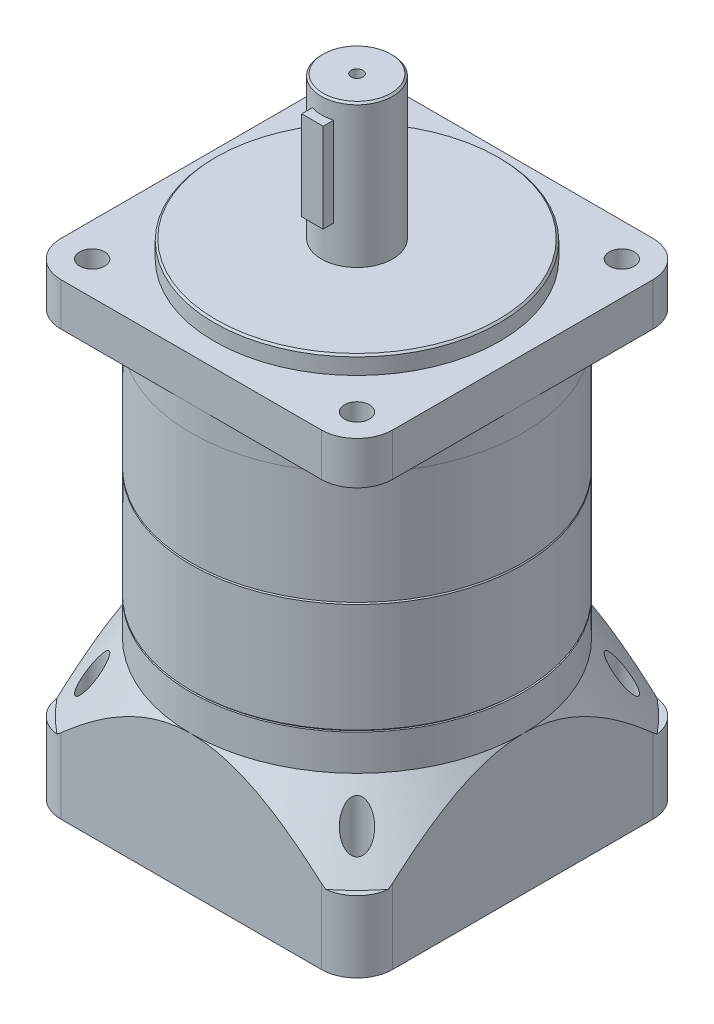
from build123d import *

# Parameters (mm, degrees)
EXTRUDE_1_DEPTH               = 49
CUT_EXTRUDE_START             = -10
SKETCH_2_OUTSIDE_W            = 123.07
SKETCH_2_OUTSIDE_H            = 123.07
SKETCH_2_OUTSIDE_R            = 46.5
CUT_EXTRUDE_3_DEPTH           = 10
CUT_EXTRUDE_3_OTHER_WAY_DEPTH = 19
CUT_EXTRUDE_3_OTHER_WAY_TAPER = 35
SKETCH_3_R                    = 46.5
EXTRUDE_2_DEPTH               = 31.5
SKETCH_18_R                   = 46.5
EXTRUDE_9_DEPTH               = 31.5
SKETCH_4_R                    = 46.5
EXTRUDE_3_DEPTH               = 19
CHAMFER_1_SIZE                = 0.5
SKETCH_6_R                    = 40
EXTRUDE_5_DEPTH               = 5
SKETCH_7_R                    = 10
EXTRUDE_6_DEPTH               = 40
CHAMFER_2_SIZE                = 0.5
SKETCH_10_W                   = 6
SKETCH_10_H                   = 25
EXTRUDE_7_DEPTH               = 12.5
SKETCH_11_R                   = 35
CUT_EXTRUDE_4_DEPTH           = 6
SKETCH_12_R                   = 10
CUT_EXTRUDE_5_DEPTH           = 40
SKETCH_15_R                   = 44.756471123
EXTRUDE_8_DEPTH               = 12
SKETCH_16_W                   = 3.5
SKETCH_16_H                   = 131
PATTERN_CIRCULAR_1_COUNT      = 4


with BuildPart() as part:
    # 草圖1 → 填料-伸長1 (new body)
    with BuildSketch(Plane(origin=(0, 0, 0), x_dir=(1, 0, 0), z_dir=(0, 1, 0))):
        with BuildLine():
            Line((-36.5, -46.5), (36.5, -46.5))
            ThreePointArc((36.5, -46.5), (43.571067812, -43.571067812), (46.5, -36.5))
            Line((46.5, -36.5), (46.5, 36.5))
            ThreePointArc((46.5, 36.5), (43.571067812, 43.571067812), (36.5, 46.5))
            Line((36.5, 46.5), (-36.5, 46.5))
            ThreePointArc((-36.5, 46.5), (-43.571067812, 43.571067812), (-46.5, 36.5))
            Line((-46.5, 36.5), (-46.5, -36.5))
            ThreePointArc((-46.5, -36.5), (-43.571067812, -43.571067812), (-36.5, -46.5))
        make_face()
    extrude(amount=EXTRUDE_1_DEPTH)

    # 草圖2 outside → 除料-伸長3 (cut)
    with BuildSketch(Plane(origin=(0, 49, 0), x_dir=(1, 0, 0), z_dir=(0, 1, 0)).offset(CUT_EXTRUDE_START)):
        Rectangle(SKETCH_2_OUTSIDE_W, SKETCH_2_OUTSIDE_H)
        with Locations(Location((0, 0, 0), (0, 0, 270))):  # turned: the seam where the file's is
            Circle(SKETCH_2_OUTSIDE_R, mode=Mode.SUBTRACT)
    extrude(amount=CUT_EXTRUDE_3_DEPTH, mode=Mode.SUBTRACT)

    # 草圖2 outside → 除料-伸長3 other way (cut)
    with BuildSketch(Plane(origin=(0, 49, 0), x_dir=(1, 0, 0), z_dir=(0, 1, 0)).offset(CUT_EXTRUDE_START)):
        Rectangle(SKETCH_2_OUTSIDE_W, SKETCH_2_OUTSIDE_H)
        with Locations(Location((0, 0, 0), (0, 0, 270))):  # turned: the seam where the file's is
            Circle(SKETCH_2_OUTSIDE_R, mode=Mode.SUBTRACT)
    extrude(amount=-CUT_EXTRUDE_3_OTHER_WAY_DEPTH, taper=CUT_EXTRUDE_3_OTHER_WAY_TAPER, mode=Mode.SUBTRACT)

    # 草圖11 → 除料-伸長4 (cut)
    with BuildSketch(Plane.XZ):
        with Locations(Location((0, 0, 0), (0, 0, 270))):  # turned: the seam where the file's is
            Circle(SKETCH_11_R)
    extrude(amount=-CUT_EXTRUDE_4_DEPTH, mode=Mode.SUBTRACT)

    # 草圖12 → 除料-伸長5 (cut)
    with BuildSketch(Plane.XZ.offset(-6)):
        with Locations(Location((0, 0, 0), (0, 0, 90))):  # turned: the seam where the file's is
            Circle(SKETCH_12_R)
    extrude(amount=-CUT_EXTRUDE_5_DEPTH, mode=Mode.SUBTRACT)


with BuildPart() as body_2:
    # 草圖3 → 填料-伸長2 (new body)
    with BuildSketch(Plane(origin=(0, 49, 0), x_dir=(1, 0, 0), z_dir=(0, 1, 0))):
        with Locations(Location((0, 0, 0), (0, 0, 270))):  # turned: the seam where the file's is
            Circle(SKETCH_3_R)
    extrude(amount=EXTRUDE_2_DEPTH)

    # 導角1
    chamfer_1_edges = [body_2.edges().sort_by_distance(p)[0] for p in [
        (0, 49, -46.5),
        (0, 80.5, -46.5),
    ]]
    chamfer(chamfer_1_edges, length=CHAMFER_1_SIZE)


with BuildPart() as body_3:
    # 草圖18 → 填料-伸長9 (new body)
    with BuildSketch(Plane(origin=(0, 80.5, 0), x_dir=(1, 0, 0), z_dir=(0, 1, 0))):
        with Locations(Location((0, 0, 0), (0, 0, 270))):  # turned: the seam where the file's is
            Circle(SKETCH_18_R)
    extrude(amount=EXTRUDE_9_DEPTH)


with BuildPart() as body_4:
    # 草圖4 → 填料-伸長3 (new body)
    with BuildSketch(Plane(origin=(0, 112, 0), x_dir=(1, 0, 0), z_dir=(0, 1, 0))):
        with Locations(Location((0, 0, 0), (0, 0, 270))):  # turned: the seam where the file's is
            Circle(SKETCH_4_R)
    extrude(amount=EXTRUDE_3_DEPTH)

    # 草圖6 → 填料-伸長5 (add)
    with BuildSketch(Plane(origin=(0, 131, 0), x_dir=(1, 0, 0), z_dir=(0, 1, 0))):
        with Locations(Location((0, 0, 0), (0, 0, 270))):  # turned: the seam where the file's is
            Circle(SKETCH_6_R)
    extrude(amount=EXTRUDE_5_DEPTH)

    # 草圖7 → 填料-伸長6 (add)
    with BuildSketch(Plane(origin=(0, 136, 0), x_dir=(1, 0, 0), z_dir=(0, 1, 0))):
        with Locations(Location((0, 0, 0), (0, 0, 270))):  # turned: the seam where the file's is
            Circle(SKETCH_7_R)
    extrude(amount=EXTRUDE_6_DEPTH)

    # 導角2
    chamfer_2_edges = [body_4.edges().sort_by_distance(p)[0] for p in [
        (0, 176, -10),
        (0, 131, -46.5),
        (0, 136, -40),
    ]]
    chamfer(chamfer_2_edges, length=CHAMFER_2_SIZE)

    # 草圖10 → 填料-伸長7 (add)
    with BuildSketch(Plane.XY):
        with Locations((0, 158.5)):
            Rectangle(SKETCH_10_W, SKETCH_10_H)
    extrude(amount=EXTRUDE_7_DEPTH)

    # 草圖13 → M4x0.7 螺紋孔1 (revolve, cut)
    with BuildSketch(Plane(origin=(0, 176, 0), x_dir=(0, 0, 1), z_dir=(1, 0, 0))):
        Polygon((0, 0), (0, 11.091420021), (1.65, 10.1), (1.65, 0), align=None)
    revolve(axis=Axis((0, 182.35, 0), (0, -1, 0)), mode=Mode.SUBTRACT)

    # 草圖15 → 填料-伸長8 (add)
    with BuildSketch(Plane(origin=(0, 131, 0), x_dir=(1, 0, 0), z_dir=(0, 1, 0))):
        with BuildLine():
            Line((-36.5, -46.5), (36.5, -46.5))
            ThreePointArc((36.5, -46.5), (43.571067812, -43.571067812), (46.5, -36.5))
            Line((46.5, -36.5), (46.5, 36.5))
            ThreePointArc((46.5, 36.5), (43.571067812, 43.571067812), (36.5, 46.5))
            Line((36.5, 46.5), (-36.5, 46.5))
            ThreePointArc((-36.5, 46.5), (-43.571067812, 43.571067812), (-46.5, 36.5))
            Line((-46.5, 36.5), (-46.5, -36.5))
            ThreePointArc((-46.5, -36.5), (-43.571067812, -43.571067812), (-36.5, -46.5))
        make_face()
        Circle(SKETCH_15_R, mode=Mode.SUBTRACT)
    extrude(amount=-EXTRUDE_8_DEPTH)


with BuildPart() as hole_wizard_7_0_7_3_tool:
    # 草圖16 → Ø7.0 (7) 直徑孔3 (revolve)
    with BuildSketch(Plane(origin=(37.123106012, 131, -37.123106012), x_dir=(0, 0, 1), z_dir=(1, 0, 0))):
        with Locations((1.75, 65.5)):
            Rectangle(SKETCH_16_W, SKETCH_16_H)
    hole_wizard_7_0_7_3 = revolve(axis=Axis((37.123106012, 137.35, -37.123106012), (0, -1, 0)))


with BuildPart() as part_1:
    add(part.part)

    # Ø7.0 (7) 直徑孔3: cut by hole_wizard_7_0_7_3_tool
    add(hole_wizard_7_0_7_3_tool.part, mode=Mode.SUBTRACT)


with BuildPart() as body_4_1:
    add(body_4.part)

    # Ø7.0 (7) 直徑孔3: cut by hole_wizard_7_0_7_3_tool
    add(hole_wizard_7_0_7_3_tool.part, mode=Mode.SUBTRACT)


with BuildPart() as pattern_circular_1_tool:
    # 環狀複製排列1: Ø7.0 (7) 直徑孔3 ×4 about axis
    pattern_circular_1_axis = Axis((0, 0, 0), (0, 1, 0))
    for i in range(1, PATTERN_CIRCULAR_1_COUNT):
        add(hole_wizard_7_0_7_3.rotate(pattern_circular_1_axis, i * 360 / PATTERN_CIRCULAR_1_COUNT))


with BuildPart() as part_2:
    add(part_1.part)

    # 環狀複製排列1: cut by pattern_circular_1_tool
    add(pattern_circular_1_tool.part, mode=Mode.SUBTRACT)


with BuildPart() as body_4_2:
    add(body_4_1.part)

    # 環狀複製排列1: cut by pattern_circular_1_tool
    add(pattern_circular_1_tool.part, mode=Mode.SUBTRACT)


solid = Compound([body_2.part, body_3.part, part_2.part, body_4_2.part])
